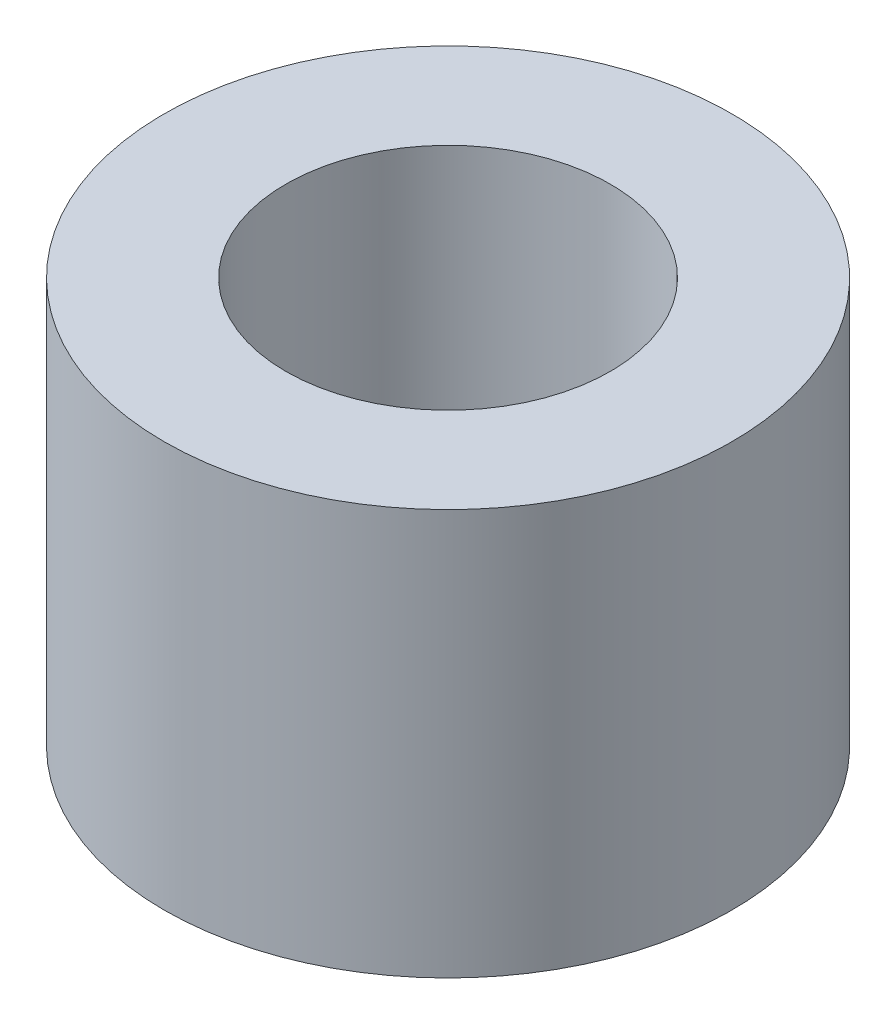
from build123d import *

# Parameters (mm, degrees)
SKETCH1_R           = 3.5
SKETCH1_R_2         = 2
BOSS_EXTRUDE2_DEPTH = 5


with BuildPart() as part:
    # Sketch1 → Boss-Extrude2 (new body)
    with BuildSketch(Plane(origin=(0, 0, 0), x_dir=(1, 0, 0), z_dir=(0, 1, 0))):
        with Locations((-8.313618314, 2.078404578)):
            Circle(SKETCH1_R)
        with Locations((-8.313618314, 2.078404578)):
            Circle(SKETCH1_R_2, mode=Mode.SUBTRACT)
    extrude(amount=BOSS_EXTRUDE2_DEPTH)


solid = part.part
